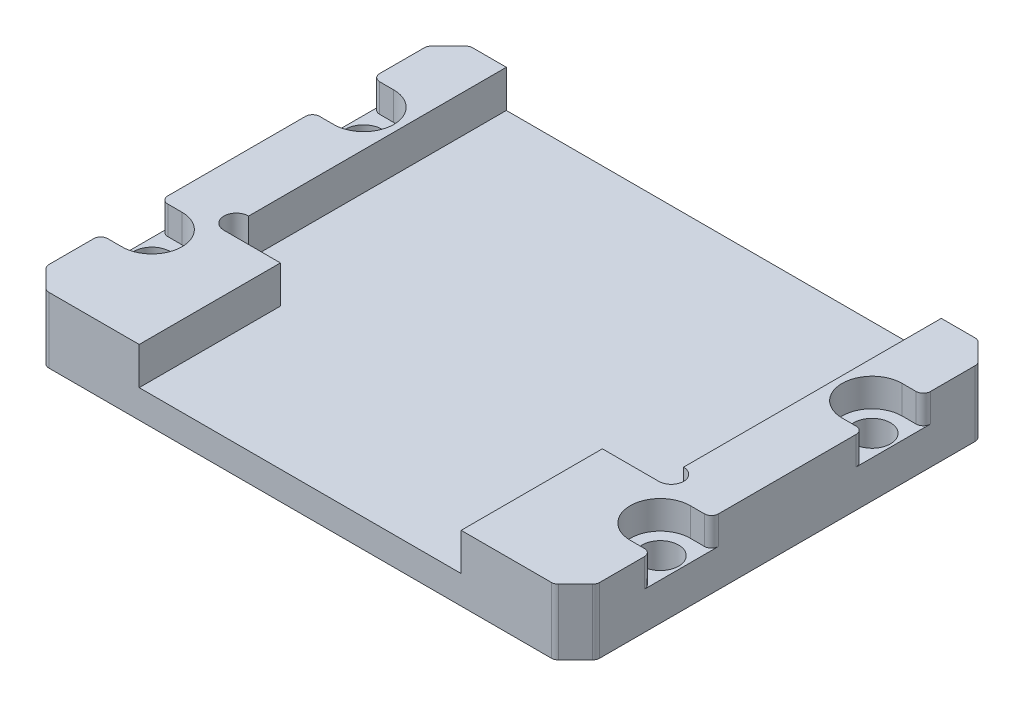
from build123d import *

# Parameters (mm, degrees)
SKETCH1_W                         = 78
SKETCH1_H                         = 60
BOSS_EXTRUDE1_DEPTH               = 9.3
TAP_DRILL_FOR_M5_TAP1_D           = 5.2
TAP_DRILL_FOR_M5_TAP1_DEPTH       = 46
TAP_DRILL_FOR_M5_TAP1_CSINK_D     = 6
TAP_DRILL_FOR_M5_TAP1_CSINK_ANGLE = 90
TAP_DRILL_FOR_M5_TAP1_TIP         = 1.562237609
SKETCH4_W                         = 61.6
SKETCH4_H                         = 60
CUT_EXTRUDE1_DEPTH                = 5.3
CHAMFER1_SIZE                     = 3
CUT_EXTRUDE2_DEPTH                = 4
FILLET1_R                         = 1
FILLET2_R                         = 1
SKETCH7_W                         = 8
SKETCH7_H                         = 20
BOSS_EXTRUDE2_DEPTH               = 5.3
SKETCH8_R                         = 1.75
CUT_EXTRUDE3_DEPTH                = 5.3


with BuildPart() as part:
    # Sketch1 → Boss-Extrude1 (new body)
    with BuildSketch(Plane(origin=(0, 0, 0), x_dir=(1, 0, 0), z_dir=(0, 1, 0))):
        Rectangle(SKETCH1_W, SKETCH1_H)
    extrude(amount=BOSS_EXTRUDE1_DEPTH)

    # Tap Drill for M5 Tap1
    with Locations(Plane(origin=(-36, 9.3, -15), x_dir=(0, 0, 1), z_dir=(0, 1, 0))):
        with Locations((0, 0), (30, 0), (30, 72), (0, 72)):
            CounterSinkHole(TAP_DRILL_FOR_M5_TAP1_D / 2, TAP_DRILL_FOR_M5_TAP1_CSINK_D / 2, depth=TAP_DRILL_FOR_M5_TAP1_DEPTH, counter_sink_angle=TAP_DRILL_FOR_M5_TAP1_CSINK_ANGLE)
            with Locations((0, 0, -(TAP_DRILL_FOR_M5_TAP1_DEPTH + TAP_DRILL_FOR_M5_TAP1_TIP / 2))):  # 118° drill point
                Cone(0, TAP_DRILL_FOR_M5_TAP1_D / 2, TAP_DRILL_FOR_M5_TAP1_TIP, mode=Mode.SUBTRACT)

    # Sketch4 → Cut-Extrude1 (cut)
    with BuildSketch(Plane(origin=(0, 9.3, 0), x_dir=(1, 0, 0), z_dir=(0, 1, 0))):
        Rectangle(SKETCH4_W, SKETCH4_H)
    extrude(amount=-CUT_EXTRUDE1_DEPTH, mode=Mode.SUBTRACT)

    # Chamfer1
    chamfer1_edges = [part.edges().sort_by_distance(p)[0] for p in [
        (39, 4.65, 30),
        (-39, 4.65, 30),
        (-39, 4.65, -30),
        (39, 4.65, -30),
    ]]
    chamfer(chamfer1_edges, length=CHAMFER1_SIZE)

    # Sketch6 → Cut-Extrude2 (cut)
    with BuildSketch(Plane(origin=(0, 9.3, 0), x_dir=(1, 0, 0), z_dir=(0, 1, 0))):
        with BuildLine():
            Line((-39.66, 19.25), (-36, 19.25))
            ThreePointArc((-36, 19.25), (-31.75, 15), (-36, 10.75))
            Line((-36, 10.75), (-39.66, 10.75))
            ThreePointArc((-39.66, 10.75), (-43.91, 15), (-39.66, 19.25))
        make_face()
        with BuildLine():
            Line((-39.66, -19.25), (-36, -19.25))
            ThreePointArc((-36, -19.25), (-31.75, -15), (-36, -10.75))
            Line((-36, -10.75), (-39.66, -10.75))
            ThreePointArc((-39.66, -10.75), (-43.91, -15), (-39.66, -19.25))
        make_face()
        with BuildLine():
            Line((39.66, 19.25), (36, 19.25))
            ThreePointArc((36, 19.25), (31.75, 15), (36, 10.75))
            Line((36, 10.75), (39.66, 10.75))
            ThreePointArc((39.66, 10.75), (43.91, 15), (39.66, 19.25))
        make_face()
        with BuildLine():
            Line((39.66, -10.75), (36, -10.75))
            ThreePointArc((36, -10.75), (31.75, -15), (36, -19.25))
            Line((36, -19.25), (39.66, -19.25))
            ThreePointArc((39.66, -19.25), (43.91, -15), (39.66, -10.75))
        make_face()
    extrude(amount=-CUT_EXTRUDE2_DEPTH, mode=Mode.SUBTRACT)

    # Fillet1
    fillet1_edges = [part.edges().sort_by_distance(p)[0] for p in [
        (-39, 4.65, 27),
        (-39, 4.65, -27),
        (36, 4.65, -30),
        (-36, 4.65, -30),
        (39, 4.65, 27),
        (39, 4.65, -27),
        (-36, 4.65, 30),
        (36, 4.65, 30),
    ]]
    fillet(fillet1_edges, radius=FILLET1_R)

    # Fillet2
    fillet2_edges = [part.edges().sort_by_distance(p)[0] for p in [
        (39, 7.3, -10.75),
        (39, 7.3, -19.25),
        (39, 7.3, 19.25),
        (39, 7.3, 10.75),
        (-39, 7.3, -19.25),
        (-39, 7.3, -10.75),
        (-39, 7.3, 19.25),
        (-39, 7.3, 10.75),
    ]]
    fillet(fillet2_edges, radius=FILLET2_R)

    # Sketch7 → Boss-Extrude2 (add)
    with BuildSketch(Plane(origin=(0, 4, 0), x_dir=(1, 0, 0), z_dir=(0, 1, 0))):
        with Locations((-26.8, -20)):
            Rectangle(SKETCH7_W, SKETCH7_H)
        with Locations((26.8, -20)):
            Rectangle(SKETCH7_W, SKETCH7_H)
    extrude(amount=BOSS_EXTRUDE2_DEPTH)

    # Sketch8 → Cut-Extrude3 (cut)
    with BuildSketch(Plane(origin=(0, 9.3, 0), x_dir=(1, 0, 0), z_dir=(0, 1, 0))):
        with Locations((30.8, -8.25)):
            Circle(SKETCH8_R)
        with Locations((-30.8, -8.25)):
            Circle(SKETCH8_R)
    extrude(amount=-CUT_EXTRUDE3_DEPTH, mode=Mode.SUBTRACT)


solid = part.part
